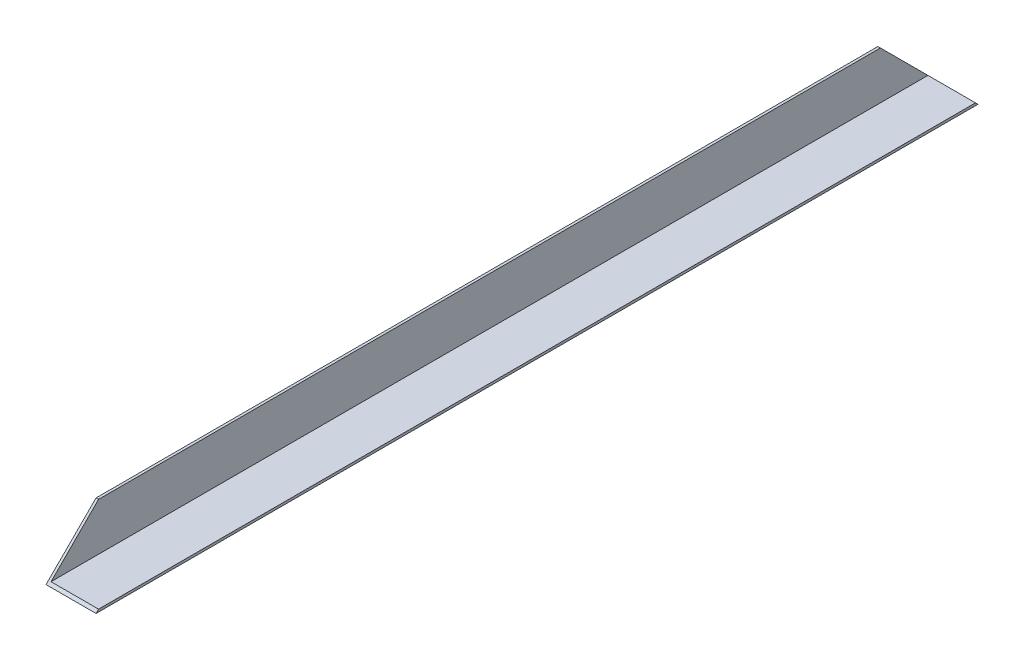
from build123d import *

# Parameters (mm, degrees)
BOSS_EXTRUDE1_DEPTH      = 304.8
BOSS_EXTRUDE1_DEPTH_BACK = 304.8
CUT_EXTRUDE1_DEPTH       = 307.909367729


with BuildPart() as part:
    # Sketch1 → Boss-Extrude1 (new, two sides: drawn at the far end of the back side and taken through both)
    with BuildSketch(Plane.XY.offset(-BOSS_EXTRUDE1_DEPTH_BACK)):
        Polygon((0, 25.4), (0, 0), (25.4, 0), (25.4, 1.27), (1.27, 1.27), (1.27, 25.4), align=None)
    extrude(amount=BOSS_EXTRUDE1_DEPTH + BOSS_EXTRUDE1_DEPTH_BACK)

    # Sketch2 → Cut-Extrude1 (cut, through all)
    with BuildSketch(Plane.ZY):
        Polygon((223.77, 0), (198.37, 25.4), (304.8, 25.4), (304.8, 0), align=None)
        Polygon((-304.8, 0), (-304.8, 25.4), (-198.37, 25.4), (-223.77, 0), align=None)
    extrude(amount=-CUT_EXTRUDE1_DEPTH, mode=Mode.SUBTRACT)


solid = part.part
